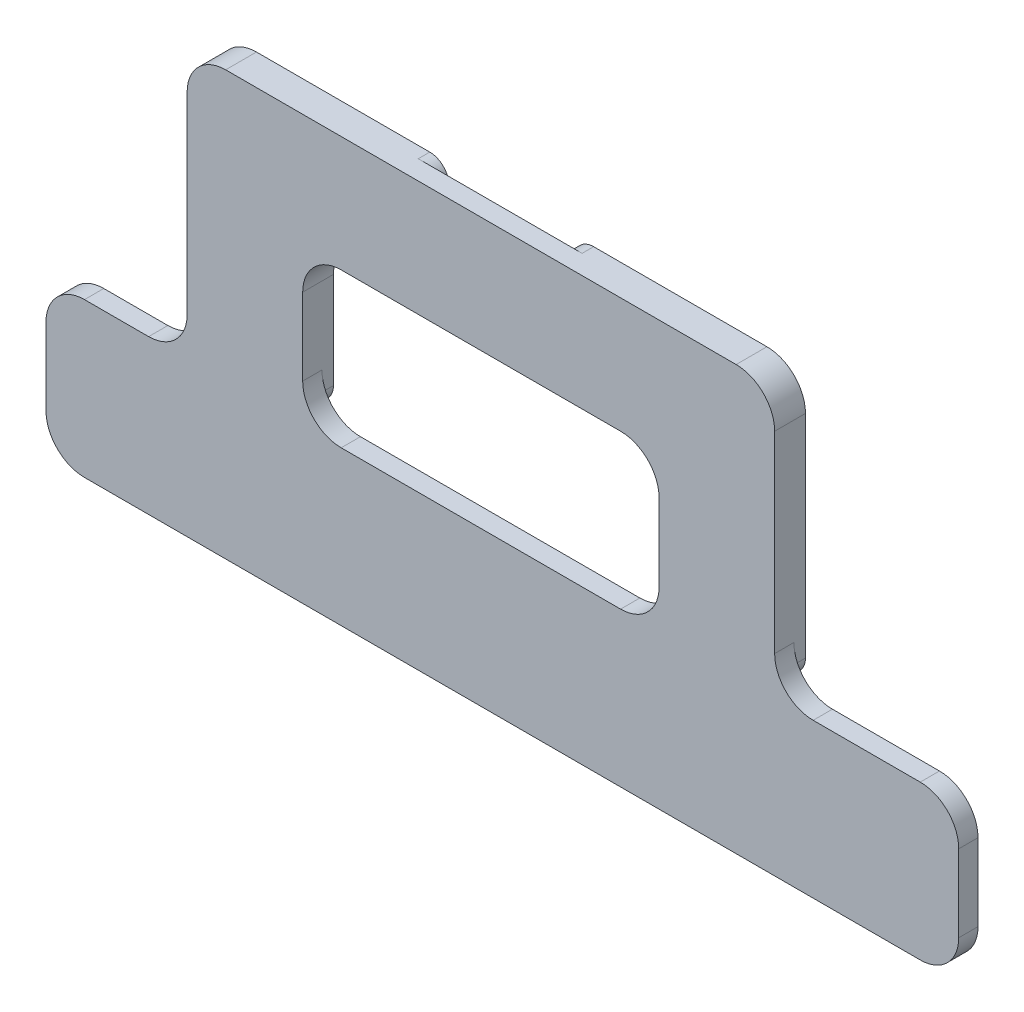
from build123d import *

# Parameters (mm, degrees)
CROQUIS1_W              = 237
CROQUIS1_H              = 40
CROQUIS1_W_2            = 32.55
CROQUIS1_H_2            = 30
SALIENTE_EXTRUIR1_DEPTH = 5
SALIENTE_EXTRUIR2_DEPTH = 3
REDONDEO1_R             = 10
REDONDEO2_R             = 5


with BuildPart() as part:
    # Croquis1 → Saliente-Extruir1 (new body)
    with BuildSketch(Plane.XY):
        Polygon((254.2, -311), (254.2, -341), (284.2, -341), (284.2, -381), (314.2, -381), (314.2, -311), align=None)
        Polygon((191.65, -341), (221.65, -341), (221.65, -311), (161.65, -311), (161.65, -381), (191.65, -381), align=None)
        with Locations((243.5, -401)):
            Rectangle(CROQUIS1_W, CROQUIS1_H)
        with Locations((237.925, -326)):
            Rectangle(CROQUIS1_W_2, CROQUIS1_H_2)
    extrude(amount=SALIENTE_EXTRUIR1_DEPTH)

    # Croquis1_3 → Saliente-Extruir2 (add)
    with BuildSketch(Plane.XY):
        Polygon((254.2, -311), (254.2, -341), (284.2, -341), (284.2, -381), (314.2, -381), (314.2, -311), align=None)
        Polygon((191.65, -341), (221.65, -341), (221.65, -311), (161.65, -311), (161.65, -381), (191.65, -381), align=None)
    extrude(amount=-SALIENTE_EXTRUIR2_DEPTH)

    # Redondeo1
    redondeo1_edges = [part.edges().sort_by_distance(p)[0] for p in [
        (314.2, -381, 2.5),
        (362, -381, 2.5),
        (362, -421, 2.5),
        (125, -421, 2.5),
        (125, -381, 2.5),
        (161.65, -381, 2.5),
        (161.65, -311, 1),
        (314.2, -311, 1),
        (191.65, -381, 2.5),
        (284.2, -381, 2.5),
        (284.2, -341, 1),
        (191.65, -341, 1),
    ]]
    fillet(redondeo1_edges, radius=REDONDEO1_R)

    # Redondeo2
    redondeo2_edges = [part.edges().sort_by_distance(p)[0] for p in [
        (314.2, -381, -1.5),
        (284.2, -381, -1.5),
        (254.2, -341, -1.5),
        (254.2, -311, -1.5),
        (221.65, -341, -1.5),
        (221.65, -311, -1.5),
        (161.65, -381, -1.5),
        (191.65, -381, -1.5),
    ]]
    fillet(redondeo2_edges, radius=REDONDEO2_R)


solid = part.part
